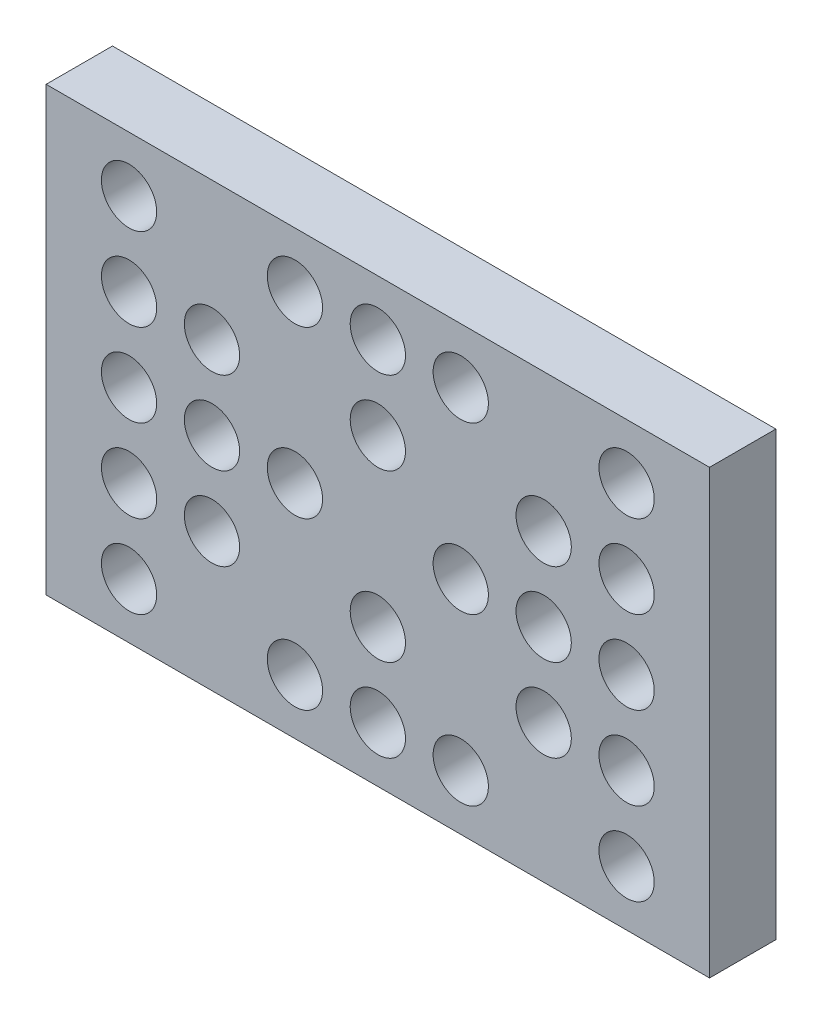
from build123d import *

# Parameters (mm, degrees)
SKICA1_W                 = 120
SKICA1_H                 = 80
P_IDAT_VYSUNUT_M1_DEPTH  = 12
SKICA2_R                 = 5
ODEBRAT_VYSUNUT_M1_DEPTH = 12
LINPOLE1_COUNT           = 7
LINPOLE1_PITCH           = 15
LINPOLE1_COUNT_DIR2      = 5
LINPOLE1_PITCH_DIR2      = 15


with BuildPart() as part:
    # Skica1 → Přidat vysunutím1 (new body)
    with BuildSketch(Plane.XY):
        Rectangle(SKICA1_W, SKICA1_H)
    extrude(amount=P_IDAT_VYSUNUT_M1_DEPTH)

    # Skica2 → Odebrat vysunutím1 (cut)
    with BuildSketch(Plane(origin=(0, 0, 0), x_dir=(-1, 0, 0), z_dir=(0, 0, -1))):
        with Locations((-45, -30)):
            Circle(SKICA2_R)
    odebrat_vysunut_m1 = extrude(amount=-ODEBRAT_VYSUNUT_M1_DEPTH, mode=Mode.SUBTRACT)

    # LinPole1: Odebrat vysunut_m1 7 × 5, 9 skipped
    with Locations(*[(-i * LINPOLE1_PITCH, j * LINPOLE1_PITCH_DIR2, 0) for i in range(LINPOLE1_COUNT) for j in range(LINPOLE1_COUNT_DIR2) if (i, j) not in ((0, 0), (1, 0), (1, 4), (2, 1), (2, 3), (3, 2), (4, 1), (4, 3), (5, 0), (5, 4))]):
        add(odebrat_vysunut_m1, mode=Mode.SUBTRACT)


solid = part.part
